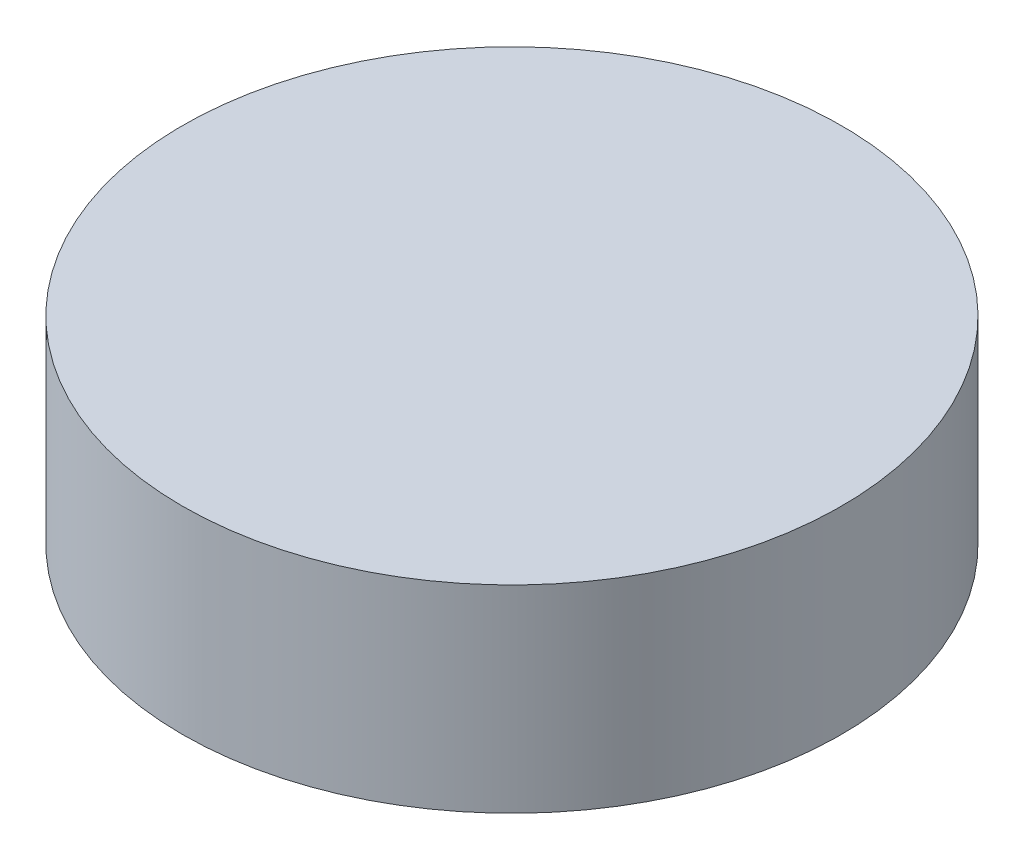
from build123d import *

# Parameters (mm, degrees)
SKETCH_1_R      = 50
EXTRUDE_1_DEPTH = 30


with BuildPart() as part:
    # 草图1 → 凸台-拉伸1 (new body)
    with BuildSketch(Plane(origin=(0, 0, 0), x_dir=(1, 0, 0), z_dir=(0, 1, 0))):
        Circle(SKETCH_1_R)
    extrude(amount=EXTRUDE_1_DEPTH)


solid = part.part
